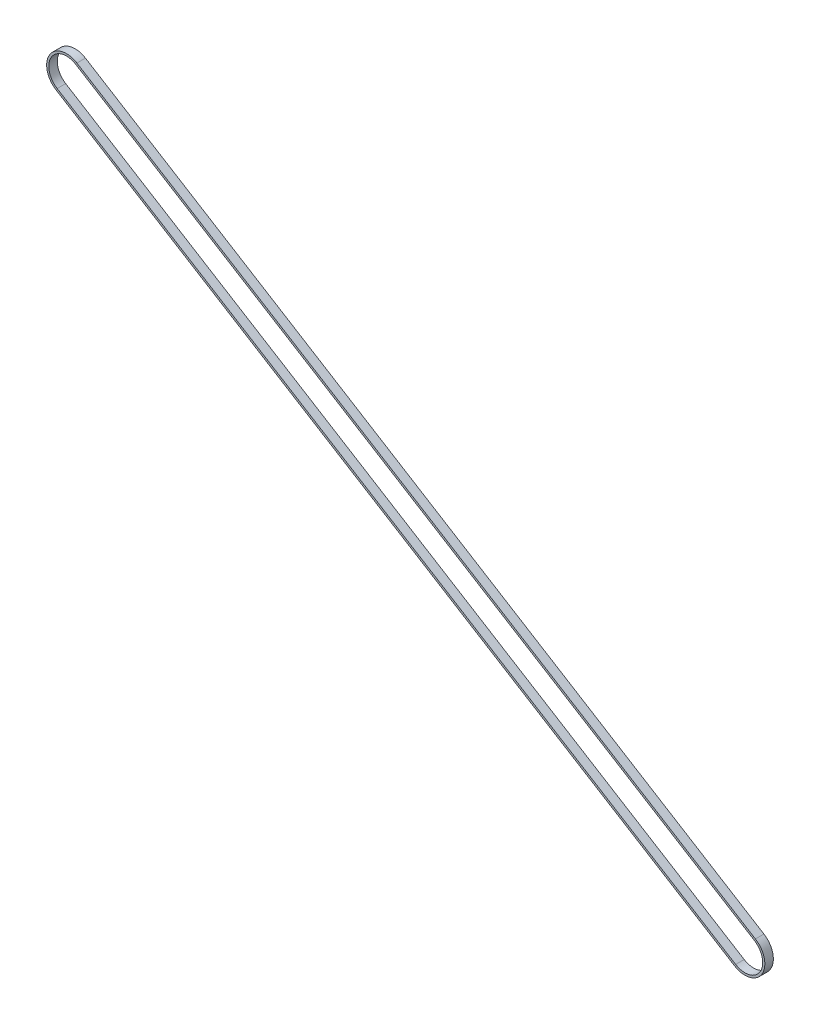
from build123d import *

# Parameters (mm, degrees)
EXTRUDE_1_DEPTH = 6


with BuildPart() as part:
    # 草图2 → 拉伸-薄壁1 (new body)
    with BuildSketch(Plane.XY):
        with BuildLine():
            Line((-470.572588548, 307.243310979), (7.346819765, 11.888013469))
            ThreePointArc((7.346819765, 11.888013469), (11.88801347, -7.34681977), (-7.346819769, -11.888013475))
            Line((-7.346819769, -11.888013475), (-485.266228081, 283.467284034))
            ThreePointArc((-485.266228081, 283.467284034), (-489.807421787, 302.702117273), (-470.572588548, 307.243310979))
        make_face()
        with BuildLine():
            Line((-471.361155965, 305.967316688), (6.558252348, 10.612019179))
            ThreePointArc((6.558252348, 10.612019179), (10.61201918, -6.558252353), (-6.558252352, -10.612019185))
            Line((-6.558252352, -10.612019185), (-484.477660664, 284.743278325))
            ThreePointArc((-484.477660664, 284.743278325), (-488.531427496, 301.913549856), (-471.361155965, 305.967316688))
        make_face(mode=Mode.SUBTRACT)
    extrude(amount=EXTRUDE_1_DEPTH)


solid = part.part
